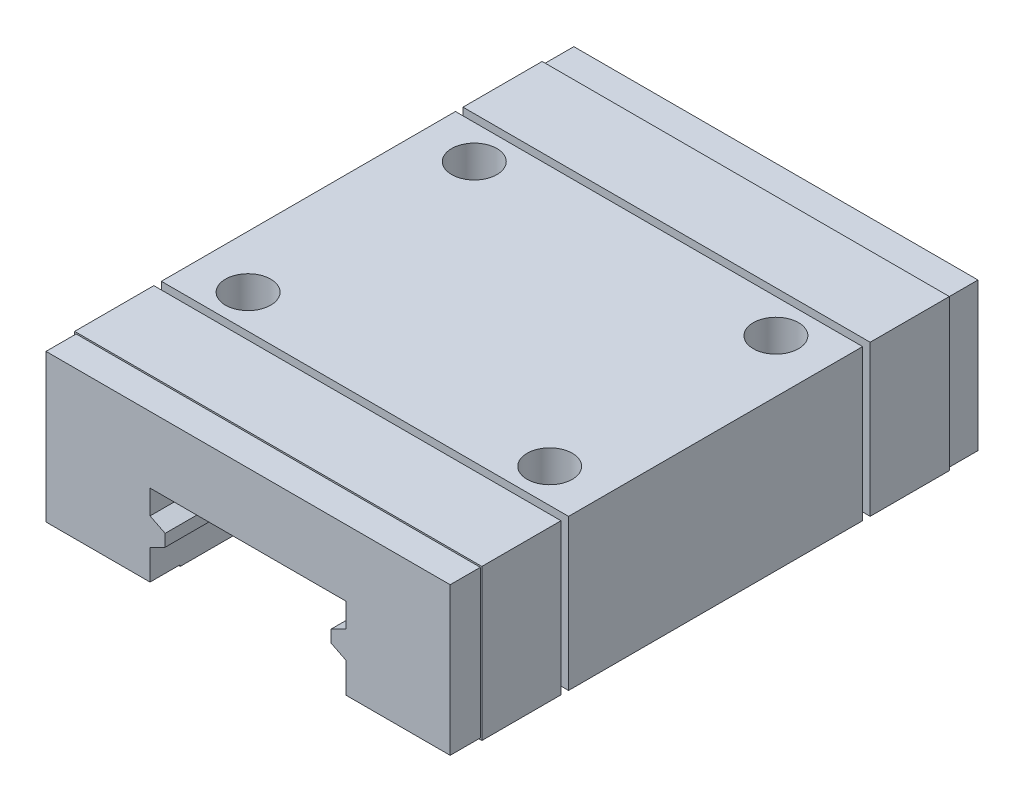
from build123d import *

# Parameters (mm, degrees)
SKETCH_2_W               = 27
SKETCH_2_H               = 10
EXTRUDE_1_DEPTH          = 17.5
SKETCH_4_R               = 1.5
CUT_EXTRUDE_1_DEPTH      = 4
SKETCH_6_W               = 27
SKETCH_6_H               = 0.5
CUT_EXTRUDE_2_DEPTH      = 0.5
SKETCH_7_W               = 0.5
SKETCH_7_H               = 9.5
CUT_EXTRUDE_3_DEPTH      = 0.5
SKETCH_12_W              = 27
SKETCH_12_H              = 10
SKETCH_12_W_2            = 26.8
SKETCH_12_H_2            = 9.8
CUT_EXTRUDE_5_DEPTH      = 2
MIRROR_3_COPY_1_SKETCH_W = 0.5
MIRROR_3_COPY_1_SKETCH_H = 9.5
MIRROR_3_COPY_1_DEPTH    = 0.5
MIRROR_3_COPY_2_SKETCH_W = 27
MIRROR_3_COPY_2_SKETCH_H = 0.5
MIRROR_3_COPY_2_DEPTH    = 0.5
SKETCH_5_W               = 13
SKETCH_5_H               = 9.581228834
CUT_EXTRUDE_4_DEPTH      = 97
EXTRUDE_3_DEPTH          = 35


with BuildPart() as part:
    # 草图2 → 凸台-拉伸1 (new body, symmetric)
    with BuildSketch(Plane.XY):
        Rectangle(SKETCH_2_W, SKETCH_2_H)
    extrude(amount=EXTRUDE_1_DEPTH, both=True)

    # 草图4 → 切除-拉伸1 (cut)
    with BuildSketch(Plane(origin=(0, 5, 0), x_dir=(1, 0, 0), z_dir=(0, 1, 0))):
        with Locations((-10, 7.5)):
            Circle(SKETCH_4_R)
        with Locations((10, 7.5)):
            Circle(SKETCH_4_R)
        with Locations((-10, -7.5)):
            Circle(SKETCH_4_R)
        with Locations((10, -7.5)):
            Circle(SKETCH_4_R)
    extrude(amount=-CUT_EXTRUDE_1_DEPTH, mode=Mode.SUBTRACT)

    # 草图6 → 切除-拉伸2 (cut)
    with BuildSketch(Plane(origin=(0, 5, 0), x_dir=(1, 0, 0), z_dir=(0, 1, 0))):
        with Locations((0, 10)):
            Rectangle(SKETCH_6_W, SKETCH_6_H)
    cut_extrude_2 = extrude(amount=-CUT_EXTRUDE_2_DEPTH, mode=Mode.SUBTRACT)

    # 草图7 → 切除-拉伸3 (cut)
    with BuildSketch(Plane.ZY.offset(13.5)):
        with Locations((-10, -0.25)):
            Rectangle(SKETCH_7_W, SKETCH_7_H)
    cut_extrude_3 = extrude(amount=-CUT_EXTRUDE_3_DEPTH, mode=Mode.SUBTRACT)

    # 草图12 → 切除-拉伸5 (cut)
    with BuildSketch(Plane(origin=(0, 0, -17.5), x_dir=(-1, 0, 0), z_dir=(0, 0, -1))):
        Rectangle(SKETCH_12_W, SKETCH_12_H)
        Rectangle(SKETCH_12_W_2, SKETCH_12_H_2, mode=Mode.SUBTRACT)
    cut_extrude_5 = extrude(amount=-CUT_EXTRUDE_5_DEPTH, mode=Mode.SUBTRACT)

    # 镜向1: 切除-拉伸2 across plane
    add(cut_extrude_2.mirror(Plane.ZX), mode=Mode.SUBTRACT)

    # 镜向2: 切除-拉伸3 across plane
    add(cut_extrude_3.mirror(Plane(origin=(0, 0, 0), x_dir=(0, 0, 1), z_dir=(1, 0, 0))), mode=Mode.SUBTRACT)

    # 镜向3: 切除-拉伸5, 切除-拉伸2, 切除-拉伸3 across plane
    add(cut_extrude_5.mirror(Plane.XY), mode=Mode.SUBTRACT)
    add(cut_extrude_2.mirror(Plane.XY), mode=Mode.SUBTRACT)
    add(cut_extrude_3.mirror(Plane.XY), mode=Mode.SUBTRACT)

    # 镜向3 copy 1 sketch → 镜向3 copy 1 (cut)
    with BuildSketch(Plane(origin=(13.5, 0, 0), x_dir=(0, 0, -1), z_dir=(1, 0, 0))):
        with Locations((-10, -0.25)):
            Rectangle(MIRROR_3_COPY_1_SKETCH_W, MIRROR_3_COPY_1_SKETCH_H)
    extrude(amount=-MIRROR_3_COPY_1_DEPTH, mode=Mode.SUBTRACT)

    # 镜向3 copy 2 sketch → 镜向3 copy 2 (cut)
    with BuildSketch(Plane.XZ.offset(5)):
        with Locations((0, 10)):
            Rectangle(MIRROR_3_COPY_2_SKETCH_W, MIRROR_3_COPY_2_SKETCH_H)
    extrude(amount=-MIRROR_3_COPY_2_DEPTH, mode=Mode.SUBTRACT)

    # 草图5 → 切除-拉伸4 (cut)
    with BuildSketch(Plane.XY.offset(17.5)):
        with Locations((0, -4.290614417)):
            Rectangle(SKETCH_5_W, SKETCH_5_H)
    extrude(amount=-CUT_EXTRUDE_4_DEPTH, mode=Mode.SUBTRACT)

    # 草图9 → 凸台-拉伸3 (add)
    with BuildSketch(Plane.XY.offset(17.5)):
        Polygon((-6.5, -1.1), (-5.5, -1.6), (-5.5, -2.4), (-6.5, -2.9), align=None)
        Polygon((5.5, -1.6), (5.5, -2.4), (6.5, -2.9), (6.5, -1.1), align=None)
    extrude(amount=-EXTRUDE_3_DEPTH)


solid = part.part
